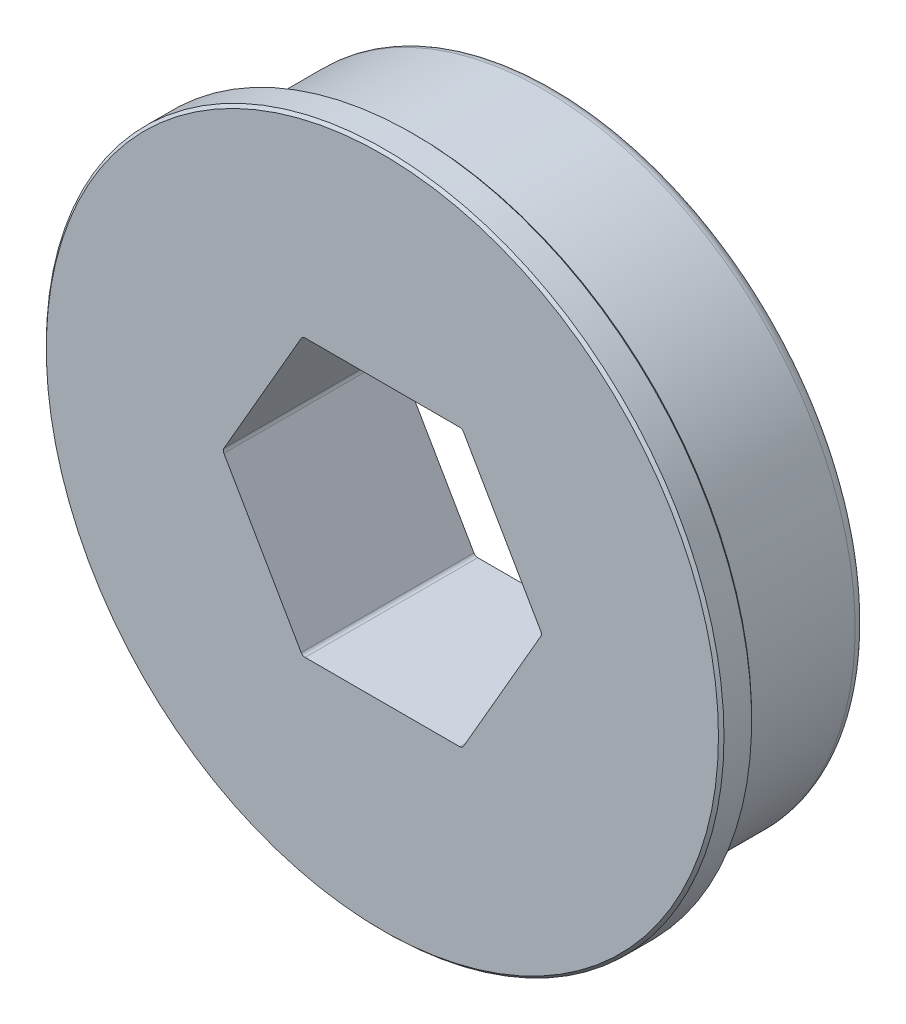
from build123d import *

# Parameters (mm, degrees)
CUT_EXTRUDE1_DEPTH = 8.92734
CHAMFER1_SIZE      = 0.127
CHAMFER2_SIZE      = 0.127
FILLET1_R          = 0.508
FILLET2_R          = 0.2032


with BuildPart() as part:
    # Sketch1 → Revolve1 (revolve)
    with BuildSketch(Plane.XZ):
        Polygon((15.5575, 7.92734), (0, 7.92734), (0, 0), (14.2875, 0), (14.2875, 5.89534), (13.97, 5.89534), (13.97, 6.40334), (15.5575, 6.40334), align=None)
    revolve(axis=Axis((0, 0, 7.92734), (0, 0, -1)))

    # Sketch2 → Cut-Extrude1 (cut, through all)
    with BuildSketch(Plane(origin=(0, 0, 0), x_dir=(-1, 0, 0), z_dir=(0, 0, -1))):
        Polygon((3.666174209, 6.35), (-3.666174209, 6.35), (-7.332348419, 0), (-3.666174209, -6.35), (3.666174209, -6.35), (7.332348419, 0), align=None)
    extrude(amount=-CUT_EXTRUDE1_DEPTH, mode=Mode.SUBTRACT)

    # Chamfer1
    chamfer1_edges = [part.edges().sort_by_distance(p)[0] for p in [
        (-15.5575, 0, 6.40334),
    ]]
    chamfer(chamfer1_edges, length=CHAMFER1_SIZE)

    # Chamfer2
    chamfer2_edges = [part.edges().sort_by_distance(p)[0] for p in [
        (-15.5575, 0, 7.92734),
    ]]
    chamfer(chamfer2_edges, length=CHAMFER2_SIZE)

    # Fillet1
    fillet1_edges = [part.edges().sort_by_distance(p)[0] for p in [
        (-14.2875, 0, 0),
    ]]
    fillet(fillet1_edges, radius=FILLET1_R)

    # Fillet2
    fillet2_edges = [part.edges().sort_by_distance(p)[0] for p in [
        (-3.666174209, 6.35, 3.96367),
        (-7.332348419, 0, 3.96367),
        (-3.666174209, -6.35, 3.96367),
        (3.666174209, -6.35, 3.96367),
        (7.332348419, 0, 3.96367),
        (3.666174209, 6.35, 3.96367),
    ]]
    fillet(fillet2_edges, radius=FILLET2_R)


solid = part.part
